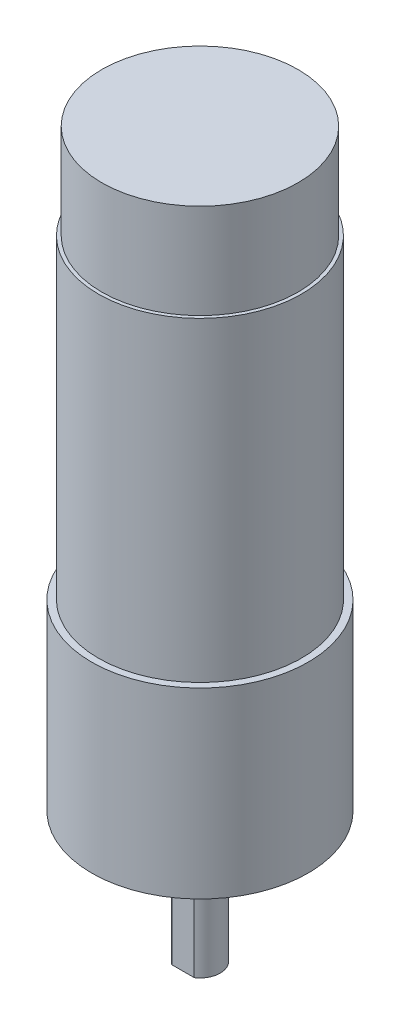
from build123d import *

# Parameters (mm, degrees)
ESQUISSE1_R             = 16
EXTRUSION1_DEPTH        = 27
EXTRUSION2_DEPTH        = 3
ESQUISSE3_R             = 3
EXTRUSION3_DEPTH        = 16.3
ENL_V_MAT_EXTRU_1_DEPTH = 12
ESQUISSE5_R             = 15
EXTRUSION4_DEPTH        = 46.6
ESQUISSE6_R             = 1.5
ENL_V_MAT_EXTRU_2_DEPTH = 5.5
ESQUISSE7_R             = 14.5
EXTRUSION5_DEPTH        = 14


with BuildPart() as part:
    # Esquisse1 → Extrusion1 (new body)
    with BuildSketch(Plane(origin=(0, 0, 0), x_dir=(1, 0, 0), z_dir=(0, 1, 0))):
        Circle(ESQUISSE1_R)
    extrude(amount=EXTRUSION1_DEPTH)

    # Esquisse2 → Extrusion2 (add)
    with BuildSketch(Plane.XZ):
        with BuildLine():
            Line((-9, 4.358898944), (-9, -4.358898944))
            ThreePointArc((-9, -4.358898944), (0, -10), (9, -4.358898944))
            Line((9, -4.358898944), (9, 4.358898944))
            ThreePointArc((9, 4.358898944), (0, 10), (-9, 4.358898944))
        make_face()
    extrude(amount=EXTRUSION2_DEPTH)

    # Esquisse3 → Extrusion3 (add)
    with BuildSketch(Plane.XZ.offset(3)):
        Circle(ESQUISSE3_R)
    extrude(amount=EXTRUSION3_DEPTH)

    # Esquisse4 → Enlèv. mat.-Extru.1 (cut)
    with BuildSketch(Plane.XZ.offset(19.3)):
        with BuildLine():
            Line((-1.658312395, 2.5), (1.658312395, 2.5))
            ThreePointArc((1.658312395, 2.5), (0, 3), (-1.658312395, 2.5))
        make_face()
    extrude(amount=-ENL_V_MAT_EXTRU_1_DEPTH, mode=Mode.SUBTRACT)

    # Esquisse5 → Extrusion4 (add)
    with BuildSketch(Plane(origin=(0, 27, 0), x_dir=(-1, 0, 0), z_dir=(0, 1, 0))):
        Circle(ESQUISSE5_R)
    extrude(amount=EXTRUSION4_DEPTH)

    # Esquisse6 → Enlèv. mat.-Extru.2 (cut)
    with BuildSketch(Plane.XZ):
        with Locations((9.192388155, 9.192388155)):
            Circle(ESQUISSE6_R)
        with Locations((-9.192388155, 9.192388155)):
            Circle(ESQUISSE6_R)
        with Locations((9.192388155, -9.192388155)):
            Circle(ESQUISSE6_R)
        with Locations((-9.192388155, -9.192388155)):
            Circle(ESQUISSE6_R)
    extrude(amount=-ENL_V_MAT_EXTRU_2_DEPTH, mode=Mode.SUBTRACT)

    # Esquisse7 → Extrusion5 (add)
    with BuildSketch(Plane(origin=(0, 73.6, 0), x_dir=(-1, 0, 0), z_dir=(0, 1, 0))):
        Circle(ESQUISSE7_R)
    extrude(amount=EXTRUSION5_DEPTH)


solid = part.part
